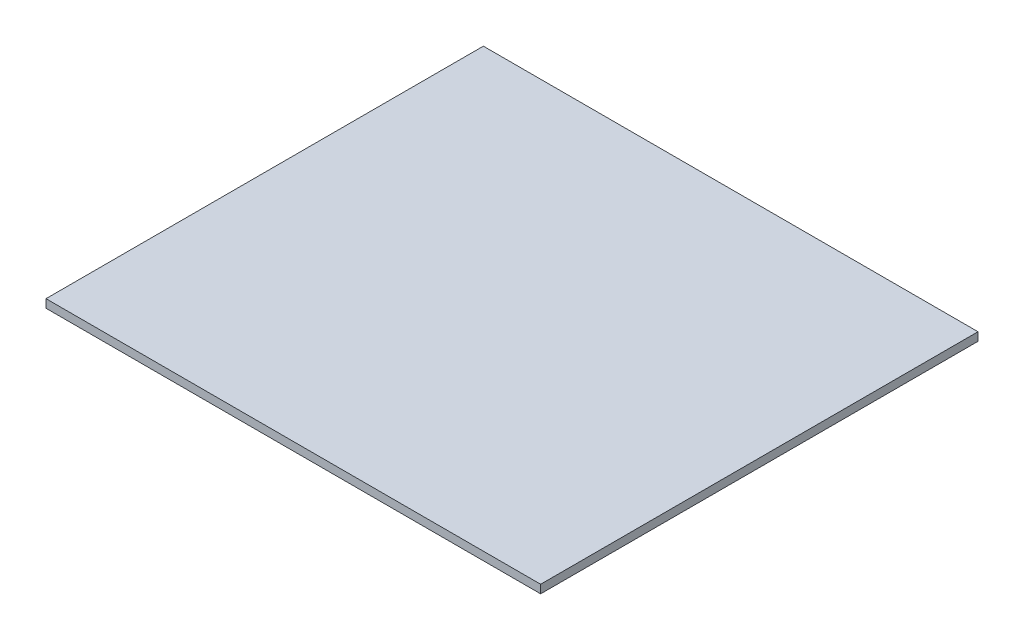
from build123d import *

# Parameters (mm, degrees)
SKETCH1_W           = 950
SKETCH1_H           = 840
BOSS_EXTRUDE1_DEPTH = 16


with BuildPart() as part:
    # Sketch1 → Boss-Extrude1 (new body)
    with BuildSketch(Plane(origin=(0, 0, 0), x_dir=(1, 0, 0), z_dir=(0, 1, 0))):
        with Locations((475, 420)):
            Rectangle(SKETCH1_W, SKETCH1_H)
    extrude(amount=BOSS_EXTRUDE1_DEPTH)


solid = part.part
